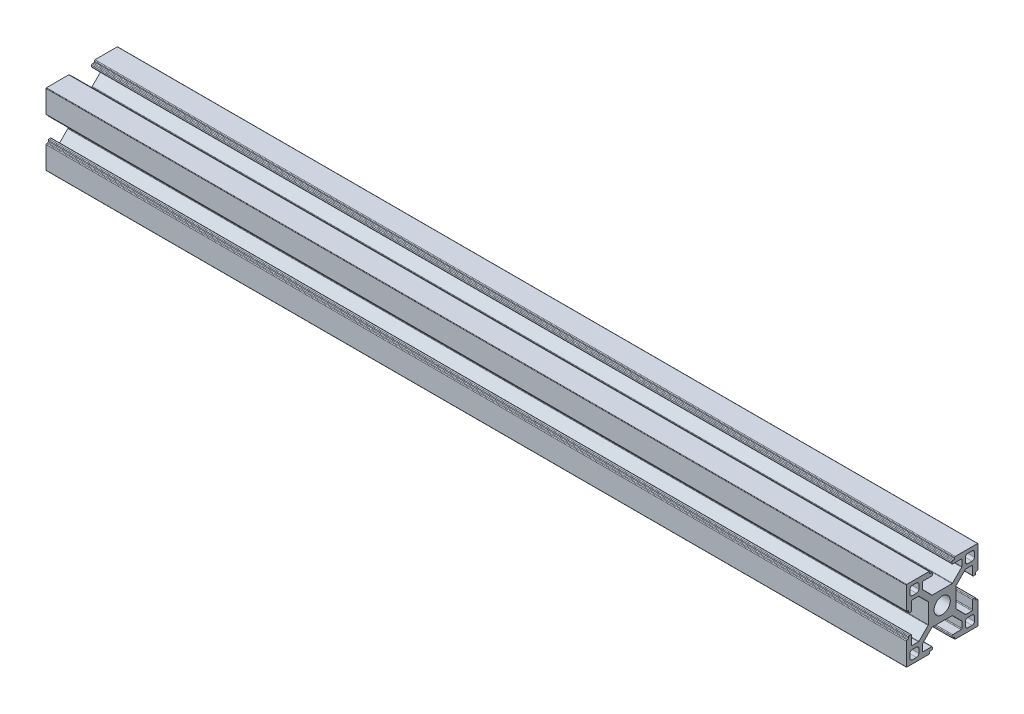
from build123d import *

# Parameters (mm, degrees)
SKETCH_11_R          = 3.4
MEMBER_3030A_1_DEPTH = 360


with BuildPart() as part:
    # 草图11 → Member 3030a _1 (new body)
    with BuildSketch(Plane.YZ):
        with BuildLine():
            Line((0, 5.8), (-4.120101013, 5.8))
            ThreePointArc((-4.120101013, 5.8), (-4.234906042, 5.82283614), (-4.332233047, 5.887867966))
            Line((-4.332233047, 5.887867966), (-8.162132034, 9.717766953))
            ThreePointArc((-8.162132034, 9.717766953), (-8.22716386, 9.815093958), (-8.25, 9.929898987))
            Line((-8.25, 9.929898987), (-8.25, 12.5))
            ThreePointArc((-8.25, 12.5), (-8.162132034, 12.712132034), (-7.95, 12.8))
            Line((-7.95, 12.8), (-4.4, 12.8))
            ThreePointArc((-4.4, 12.8), (-4.187867966, 12.887867966), (-4.1, 13.1))
            Line((-4.1, 13.1), (-4.1, 13.7))
            ThreePointArc((-4.1, 13.7), (-4.187867966, 13.912132034), (-4.4, 14))
            Line((-4.4, 14), (-4.9, 14))
            ThreePointArc((-4.9, 14), (-5.112132034, 14.087867966), (-5.2, 14.3))
            Line((-5.2, 14.3), (-5.2, 14.7))
            ThreePointArc((-5.2, 14.7), (-5.287867966, 14.912132034), (-5.5, 15))
            Line((-5.5, 15), (-14.8, 15))
            ThreePointArc((-14.8, 15), (-14.941421356, 14.941421356), (-15, 14.8))
            Line((-15, 14.8), (-15, 5.5))
            ThreePointArc((-15, 5.5), (-14.912132034, 5.287867966), (-14.7, 5.2))
            Line((-14.7, 5.2), (-14.3, 5.2))
            ThreePointArc((-14.3, 5.2), (-14.087867966, 5.112132034), (-14, 4.9))
            Line((-14, 4.9), (-14, 4.4))
            ThreePointArc((-14, 4.4), (-13.912132034, 4.187867966), (-13.7, 4.1))
            Line((-13.7, 4.1), (-13.1, 4.1))
            ThreePointArc((-13.1, 4.1), (-12.887867966, 4.187867966), (-12.8, 4.4))
            Line((-12.8, 4.4), (-12.8, 7.95))
            ThreePointArc((-12.8, 7.95), (-12.712132034, 8.162132034), (-12.5, 8.25))
            Line((-12.5, 8.25), (-9.929898987, 8.25))
            ThreePointArc((-9.929898987, 8.25), (-9.815093957, 8.227163859), (-9.717766953, 8.162132034))
            Line((-9.717766953, 8.162132034), (-5.887867966, 4.332233047))
            ThreePointArc((-5.887867966, 4.332233047), (-5.82283614, 4.234906042), (-5.8, 4.120101013))
            Line((-5.8, 4.120101013), (-5.8, 0))
            Line((-5.8, 0), (-5.8, -4.120101013))
            ThreePointArc((-5.8, -4.120101013), (-5.82283614, -4.234906042), (-5.887867966, -4.332233047))
            Line((-5.887867966, -4.332233047), (-9.717766953, -8.162132034))
            ThreePointArc((-9.717766953, -8.162132034), (-9.815093958, -8.22716386), (-9.929898988, -8.25))
            Line((-9.929898988, -8.25), (-12.5, -8.25))
            ThreePointArc((-12.5, -8.25), (-12.712132034, -8.162132034), (-12.8, -7.95))
            Line((-12.8, -7.95), (-12.8, -4.4))
            ThreePointArc((-12.8, -4.4), (-12.887867966, -4.187867966), (-13.1, -4.1))
            Line((-13.1, -4.1), (-13.7, -4.1))
            ThreePointArc((-13.7, -4.1), (-13.912132034, -4.187867966), (-14, -4.4))
            Line((-14, -4.4), (-14, -4.9))
            ThreePointArc((-14, -4.9), (-14.087867966, -5.112132034), (-14.3, -5.2))
            Line((-14.3, -5.2), (-14.7, -5.2))
            ThreePointArc((-14.7, -5.2), (-14.912132034, -5.287867966), (-15, -5.5))
            Line((-15, -5.5), (-15, -14.8))
            ThreePointArc((-15, -14.8), (-14.941421356, -14.941421356), (-14.8, -15))
            Line((-14.8, -15), (-5.5, -15))
            ThreePointArc((-5.5, -15), (-5.287867966, -14.912132034), (-5.2, -14.7))
            Line((-5.2, -14.7), (-5.2, -14.3))
            ThreePointArc((-5.2, -14.3), (-5.112132034, -14.087867966), (-4.9, -14))
            Line((-4.9, -14), (-4.4, -14))
            ThreePointArc((-4.4, -14), (-4.187867966, -13.912132034), (-4.1, -13.7))
            Line((-4.1, -13.7), (-4.1, -13.1))
            ThreePointArc((-4.1, -13.1), (-4.187867966, -12.887867966), (-4.4, -12.8))
            Line((-4.4, -12.8), (-7.95, -12.8))
            ThreePointArc((-7.95, -12.8), (-8.162132034, -12.712132034), (-8.25, -12.5))
            Line((-8.25, -12.5), (-8.25, -9.929898987))
            ThreePointArc((-8.25, -9.929898987), (-8.22716386, -9.815093958), (-8.162132034, -9.717766953))
            Line((-8.162132034, -9.717766953), (-4.332233047, -5.887867966))
            ThreePointArc((-4.332233047, -5.887867966), (-4.234906042, -5.82283614), (-4.120101013, -5.8))
            Line((-4.120101013, -5.8), (0, -5.8))
            Line((0, -5.8), (4.120101013, -5.8))
            ThreePointArc((4.120101013, -5.8), (4.234906042, -5.82283614), (4.332233047, -5.887867966))
            Line((4.332233047, -5.887867966), (8.162132034, -9.717766953))
            ThreePointArc((8.162132034, -9.717766953), (8.22716386, -9.815093958), (8.25, -9.929898987))
            Line((8.25, -9.929898987), (8.25, -12.5))
            ThreePointArc((8.25, -12.5), (8.162132034, -12.712132034), (7.95, -12.8))
            Line((7.95, -12.8), (4.4, -12.8))
            ThreePointArc((4.4, -12.8), (4.187867966, -12.887867966), (4.1, -13.1))
            Line((4.1, -13.1), (4.1, -13.7))
            ThreePointArc((4.1, -13.7), (4.187867966, -13.912132034), (4.4, -14))
            Line((4.4, -14), (4.9, -14))
            ThreePointArc((4.9, -14), (5.112132034, -14.087867966), (5.2, -14.3))
            Line((5.2, -14.3), (5.2, -14.7))
            ThreePointArc((5.2, -14.7), (5.287867966, -14.912132034), (5.5, -15))
            Line((5.5, -15), (14.8, -15))
            ThreePointArc((14.8, -15), (14.941421356, -14.941421356), (15, -14.8))
            Line((15, -14.8), (15, -5.5))
            ThreePointArc((15, -5.5), (14.912132034, -5.287867966), (14.7, -5.2))
            Line((14.7, -5.2), (14.3, -5.2))
            ThreePointArc((14.3, -5.2), (14.087867966, -5.112132034), (14, -4.9))
            Line((14, -4.9), (14, -4.4))
            ThreePointArc((14, -4.4), (13.912132034, -4.187867966), (13.7, -4.1))
            Line((13.7, -4.1), (13.1, -4.1))
            ThreePointArc((13.1, -4.1), (12.887867966, -4.187867966), (12.8, -4.4))
            Line((12.8, -4.4), (12.8, -7.95))
            ThreePointArc((12.8, -7.95), (12.712132034, -8.162132034), (12.5, -8.25))
            Line((12.5, -8.25), (9.929898987, -8.25))
            ThreePointArc((9.929898987, -8.25), (9.815093957, -8.227163859), (9.717766953, -8.162132034))
            Line((9.717766953, -8.162132034), (5.887867966, -4.332233047))
            ThreePointArc((5.887867966, -4.332233047), (5.82283614, -4.234906042), (5.8, -4.120101013))
            Line((5.8, -4.120101013), (5.8, 0))
            Line((5.8, 0), (5.8, 4.120101013))
            ThreePointArc((5.8, 4.120101013), (5.82283614, 4.234906042), (5.887867966, 4.332233047))
            Line((5.887867966, 4.332233047), (9.805634919, 8.25))
            Line((9.805634919, 8.25), (12.5, 8.25))
            ThreePointArc((12.5, 8.25), (12.712132034, 8.162132034), (12.8, 7.95))
            Line((12.8, 7.95), (12.8, 4.4))
            ThreePointArc((12.8, 4.4), (12.887867966, 4.187867966), (13.1, 4.1))
            Line((13.1, 4.1), (13.7, 4.1))
            ThreePointArc((13.7, 4.1), (13.912132034, 4.187867966), (14, 4.4))
            Line((14, 4.4), (14, 4.9))
            ThreePointArc((14, 4.9), (14.087867966, 5.112132034), (14.3, 5.2))
            Line((14.3, 5.2), (14.7, 5.2))
            ThreePointArc((14.7, 5.2), (14.912132034, 5.287867966), (15, 5.5))
            Line((15, 5.5), (15, 14.8))
            ThreePointArc((15, 14.8), (14.941421356, 14.941421356), (14.8, 15))
            Line((14.8, 15), (5.5, 15))
            ThreePointArc((5.5, 15), (5.287867966, 14.912132034), (5.2, 14.7))
            Line((5.2, 14.7), (5.2, 14.3))
            ThreePointArc((5.2, 14.3), (5.112132034, 14.087867966), (4.9, 14))
            Line((4.9, 14), (4.4, 14))
            ThreePointArc((4.4, 14), (4.187867966, 13.912132034), (4.1, 13.7))
            Line((4.1, 13.7), (4.1, 13.1))
            ThreePointArc((4.1, 13.1), (4.187867966, 12.887867966), (4.4, 12.8))
            Line((4.4, 12.8), (7.95, 12.8))
            ThreePointArc((7.95, 12.8), (8.162132034, 12.712132034), (8.25, 12.5))
            Line((8.25, 12.5), (8.25, 9.929898987))
            ThreePointArc((8.25, 9.929898987), (8.22716386, 9.815093958), (8.162132034, 9.717766953))
            Line((8.162132034, 9.717766953), (4.332233047, 5.887867966))
            ThreePointArc((4.332233047, 5.887867966), (4.234906042, 5.82283614), (4.120101013, 5.8))
            Line((4.120101013, 5.8), (0, 5.8))
        make_face()
        Circle(SKETCH_11_R, mode=Mode.SUBTRACT)
        with BuildLine():
            Line((-10.75, -13.5), (-12.5, -13.5))
            ThreePointArc((-12.5, -13.5), (-13.207106781, -13.207106781), (-13.5, -12.5))
            Line((-13.5, -12.5), (-13.5, -10.75))
            ThreePointArc((-13.5, -10.75), (-13.207106781, -10.042893219), (-12.5, -9.75))
            Line((-12.5, -9.75), (-10.75, -9.75))
            ThreePointArc((-10.75, -9.75), (-10.042893219, -10.042893219), (-9.75, -10.75))
            Line((-9.75, -10.75), (-9.75, -12.5))
            ThreePointArc((-9.75, -12.5), (-10.042893219, -13.207106781), (-10.75, -13.5))
        make_face(mode=Mode.SUBTRACT)
        with BuildLine():
            Line((10.75, -13.5), (12.5, -13.5))
            ThreePointArc((12.5, -13.5), (13.207106781, -13.207106781), (13.5, -12.5))
            Line((13.5, -12.5), (13.5, -10.75))
            ThreePointArc((13.5, -10.75), (13.207106781, -10.042893219), (12.5, -9.75))
            Line((12.5, -9.75), (10.75, -9.75))
            ThreePointArc((10.75, -9.75), (10.042893219, -10.042893219), (9.75, -10.75))
            Line((9.75, -10.75), (9.75, -12.5))
            ThreePointArc((9.75, -12.5), (10.042893219, -13.207106781), (10.75, -13.5))
        make_face(mode=Mode.SUBTRACT)
        with BuildLine():
            Line((-10.75, 13.5), (-12.5, 13.5))
            ThreePointArc((-12.5, 13.5), (-13.207106781, 13.207106781), (-13.5, 12.5))
            Line((-13.5, 12.5), (-13.5, 10.75))
            ThreePointArc((-13.5, 10.75), (-13.207106781, 10.042893219), (-12.5, 9.75))
            Line((-12.5, 9.75), (-10.75, 9.75))
            ThreePointArc((-10.75, 9.75), (-10.042893219, 10.042893219), (-9.75, 10.75))
            Line((-9.75, 10.75), (-9.75, 12.5))
            ThreePointArc((-9.75, 12.5), (-10.042893219, 13.207106781), (-10.75, 13.5))
        make_face(mode=Mode.SUBTRACT)
        with BuildLine():
            Line((10.75, 13.5), (12.5, 13.5))
            ThreePointArc((12.5, 13.5), (13.207106781, 13.207106781), (13.5, 12.5))
            Line((13.5, 12.5), (13.5, 10.75))
            ThreePointArc((13.5, 10.75), (13.207106781, 10.042893219), (12.5, 9.75))
            Line((12.5, 9.75), (10.75, 9.75))
            ThreePointArc((10.75, 9.75), (10.042893219, 10.042893219), (9.75, 10.75))
            Line((9.75, 10.75), (9.75, 12.5))
            ThreePointArc((9.75, 12.5), (10.042893219, 13.207106781), (10.75, 13.5))
        make_face(mode=Mode.SUBTRACT)
    extrude(amount=MEMBER_3030A_1_DEPTH)


solid = part.part
